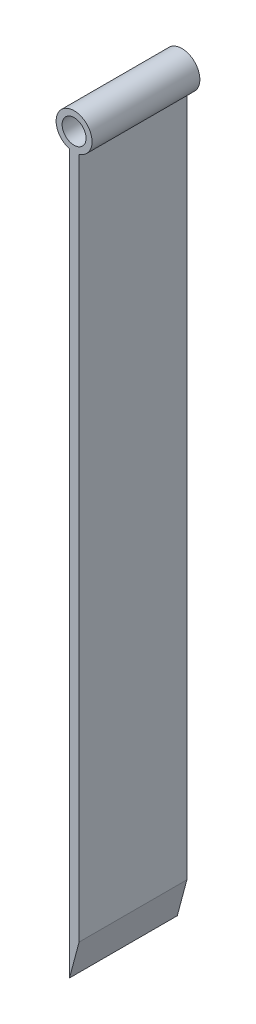
from build123d import *

# Parameters (mm, degrees)
CROQUIS1_R              = 3.75
CROQUIS1_R_2            = 2.5
SALIENTE_EXTRUIR1_DEPTH = 22.5


with BuildPart() as part:
    # Croquis1 → Saliente-Extruir1 (new body)
    with BuildSketch(Plane.XY):
        with Locations((0.957931978, 153.5)):
            Circle(CROQUIS1_R)
        with Locations((0.957931978, 153.5)):
            Circle(CROQUIS1_R_2, mode=Mode.SUBTRACT)
        with BuildLine():
            ThreePointArc((2, 149.897695982), (1.001580793, 149.750254038), (0, 149.874415037))
            Line((0, 149.874415037), (0, 0))
            Line((0, 0), (2, 7.5))
            Line((2, 7.5), (2, 149.897695982))
        make_face()
    extrude(amount=SALIENTE_EXTRUIR1_DEPTH)


solid = part.part
